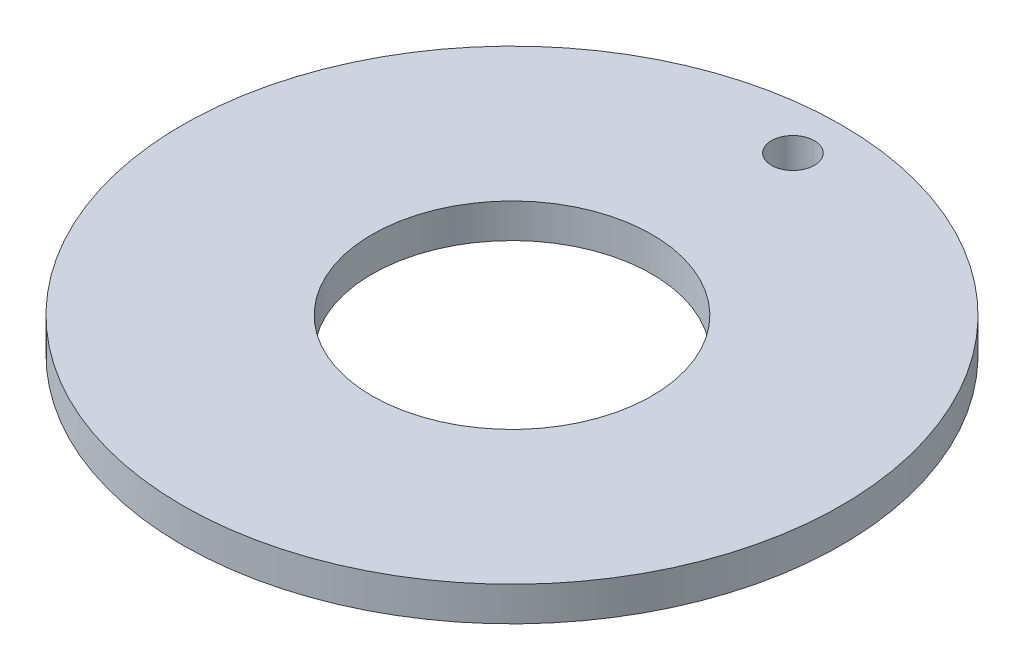
from build123d import *

# Parameters (mm, degrees)
SKETCH1_R                      = 61
SKETCH1_R_2                    = 25.9
BOSS_EXTRUDE1_DEPTH            = 6.35
F_5_16_0_3125_DIAMETER_HOLE1_D = 7.9375


with BuildPart() as part:
    # Sketch1 → Boss-Extrude1 (new body)
    with BuildSketch(Plane(origin=(0, 0, 0), x_dir=(1, 0, 0), z_dir=(0, 1, 0))):
        with Locations(Location((0, 0, 0), (0, 0, 270))):  # turned: the seam where the file's is
            Circle(SKETCH1_R)
        with Locations(Location((0, 0, 0), (0, 0, 270))):  # turned: the seam where the file's is
            Circle(SKETCH1_R_2, mode=Mode.SUBTRACT)
    extrude(amount=BOSS_EXTRUDE1_DEPTH)

    # 5/16 (0.3125) Diameter Hole1 (through all)
    with Locations(Plane(origin=(0, 6.35, 0), x_dir=(1, 0, 0), z_dir=(0, 1, 0))):
        with Locations((0, 52)):
            Hole(F_5_16_0_3125_DIAMETER_HOLE1_D / 2)


solid = part.part
